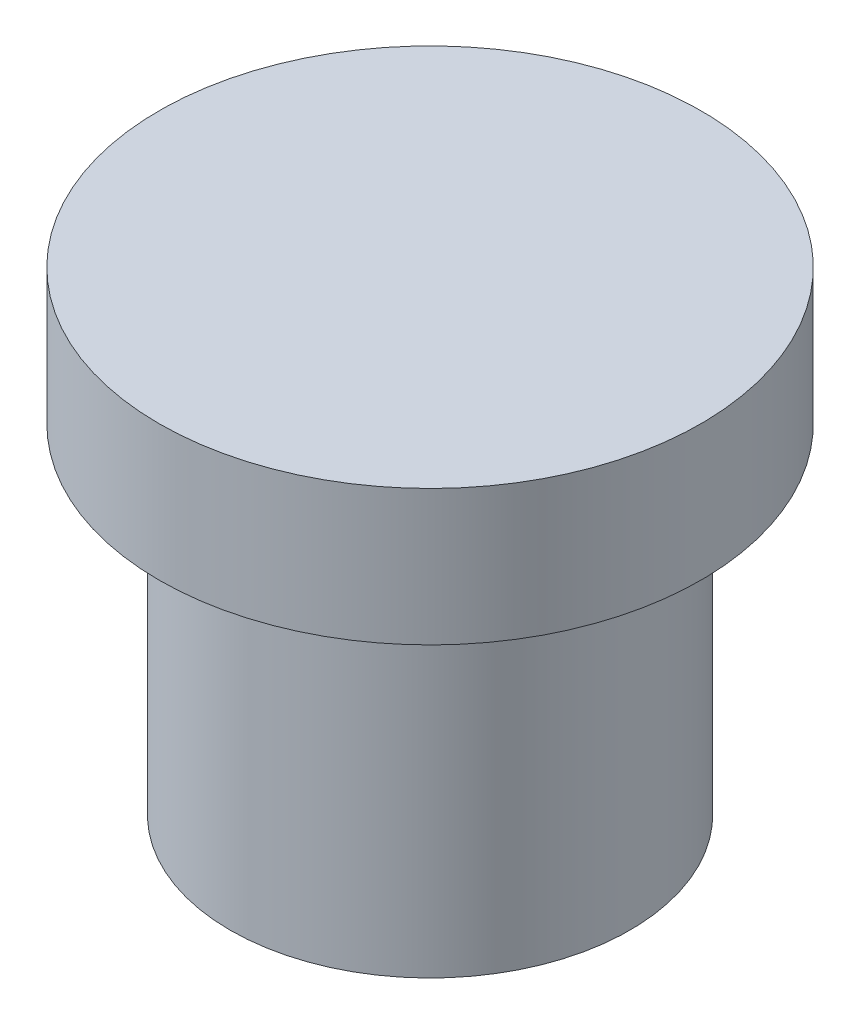
from build123d import *

# Parameters (mm, degrees)
SKETCH1_R           = 2.95
BOSS_EXTRUDE1_DEPTH = 5
SKETCH2_R           = 4
BOSS_EXTRUDE2_DEPTH = 2


with BuildPart() as part:
    # Sketch1 → Boss-Extrude1 (new body)
    with BuildSketch(Plane(origin=(0, 0, 0), x_dir=(1, 0, 0), z_dir=(0, 1, 0))):
        Circle(SKETCH1_R)
    extrude(amount=BOSS_EXTRUDE1_DEPTH)

    # Sketch2 → Boss-Extrude2 (add)
    with BuildSketch(Plane(origin=(0, 5, 0), x_dir=(1, 0, 0), z_dir=(0, 1, 0))):
        Circle(SKETCH2_R)
    extrude(amount=BOSS_EXTRUDE2_DEPTH)


solid = part.part
